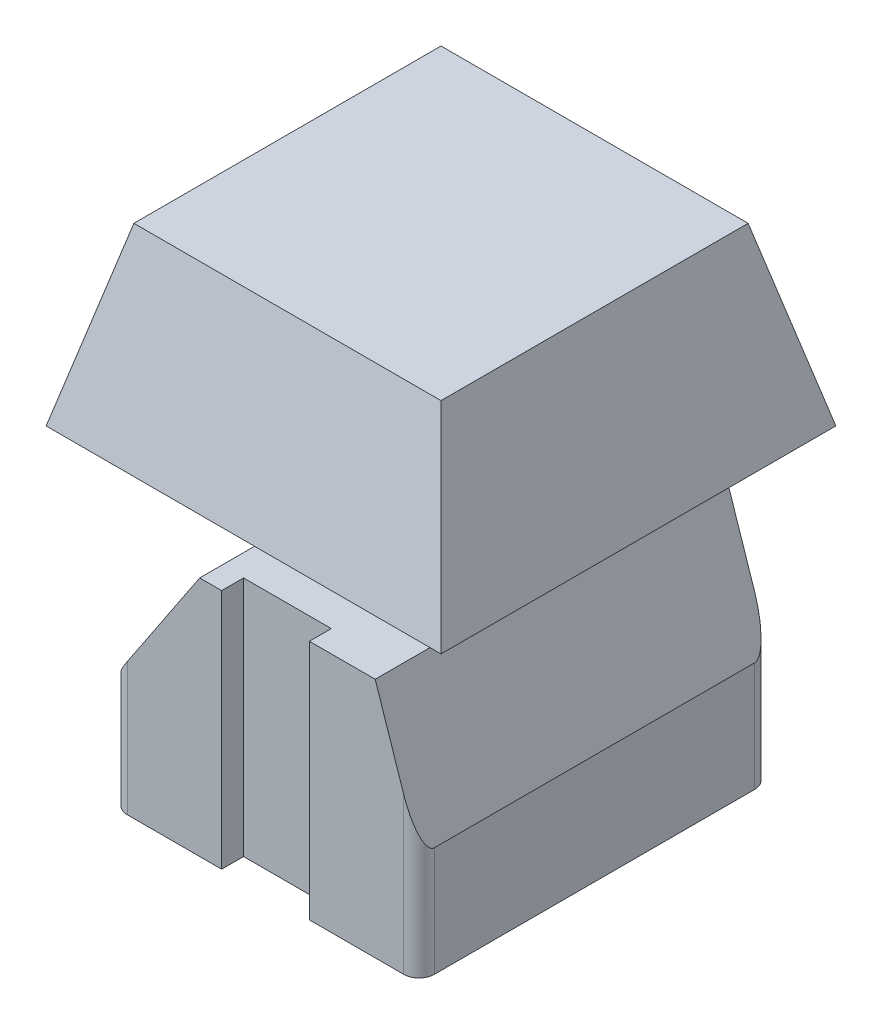
from build123d import *

# Parameters (mm, degrees)
BOSS_EXTRUDE1_DEPTH = 11
CUT_EXTRUDE1_DEPTH  = 18
CUT_EXTRUDE2_DEPTH  = 18
BOSS_EXTRUDE2_DEPTH = 3.5
BOSS_EXTRUDE3_DEPTH = 8
CUT_EXTRUDE4_DEPTH  = 27
CUT_EXTRUDE5_DEPTH  = 27
SKETCH11_W          = 14.6
SKETCH11_H          = 0.1
BOSS_EXTRUDE4_DEPTH = 0.1


with BuildPart() as part:
    # Sketch1 → Boss-Extrude1 (new body)
    with BuildSketch(Plane(origin=(0, 0, 0), x_dir=(1, 0, 0), z_dir=(0, 1, 0))):
        with BuildLine():
            Line((-6.3, -8), (-2, -8))
            Line((-2, -8), (-2, -7))
            Line((-2, -7), (2, -7))
            Line((2, -7), (2, -8))
            Line((2, -8), (6.3, -8))
            ThreePointArc((6.3, -8), (6.794974747, -7.794974747), (7, -7.3))
            Line((7, -7.3), (7, 7.3))
            ThreePointArc((7, 7.3), (6.794974747, 7.794974747), (6.3, 8))
            Line((6.3, 8), (2, 8))
            Line((2, 8), (2, 7))
            Line((2, 7), (-2, 7))
            Line((-2, 7), (-2, 8))
            Line((-2, 8), (-6.3, 8))
            ThreePointArc((-6.3, 8), (-6.794974747, 7.794974747), (-7, 7.3))
            Line((-7, 7.3), (-7, -7.3))
            ThreePointArc((-7, -7.3), (-6.794974747, -7.794974747), (-6.3, -8))
        make_face()
    extrude(amount=BOSS_EXTRUDE1_DEPTH)

    # Sketch2 → Cut-Extrude1 (cut)
    with BuildSketch(Plane.XY.offset(8)):
        Polygon((-3, 11), (-7, 5), (-7, 11), align=None)
    extrude(amount=-CUT_EXTRUDE1_DEPTH, mode=Mode.SUBTRACT)

    # Sketch3 → Cut-Extrude2 (cut)
    with BuildSketch(Plane.XY.offset(8)):
        Polygon((5, 11), (7, 5), (7, 11), align=None)
    extrude(amount=-CUT_EXTRUDE2_DEPTH, mode=Mode.SUBTRACT)

    # Sketch4 → Boss-Extrude2 (add)
    with BuildSketch(Plane(origin=(0, 11, 0), x_dir=(1, 0, 0), z_dir=(0, 1, 0))):
        Polygon((-0.75, 0.75), (-0.75, 2), (0.75, 2), (0.75, 0.75), (2, 0.75), (2, -0.75), (0.75, -0.75), (0.75, -2), (-0.75, -2), (-0.75, -0.75), (-2, -0.75), (-2, 0.75), align=None)
    extrude(amount=BOSS_EXTRUDE2_DEPTH)

    # Sketch7 → Boss-Extrude3 (add)
    with BuildSketch(Plane(origin=(0, 14.5, 0), x_dir=(1, 0, 0), z_dir=(0, 1, 0))):
        Polygon((9, -9), (-9, -9), (-9, 9), (0, 9), (9, 9), align=None)
    extrude(amount=BOSS_EXTRUDE3_DEPTH)

    # Sketch10 → Cut-Extrude4 (cut)
    with BuildSketch(Plane.ZY.offset(9)):
        Polygon((-9, 22.5), (-7, 22.5), (-9, 14.5), align=None)
        Polygon((7, 22.5), (9, 22.5), (9, 14.5), align=None)
    extrude(amount=-CUT_EXTRUDE4_DEPTH, mode=Mode.SUBTRACT)

    # Sketch8 → Cut-Extrude5 (cut)
    with BuildSketch(Plane(origin=(0, 0, -9), x_dir=(-1, 0, 0), z_dir=(0, 0, -1))):
        Polygon((9, 22.5), (7, 22.5), (9, 14.5), align=None)
        Polygon((-9, 22.5), (-7, 22.5), (-9, 14.5), align=None)
    extrude(amount=-CUT_EXTRUDE5_DEPTH, mode=Mode.SUBTRACT)

    # Sketch11 → Boss-Extrude4 (add)
    with BuildSketch(Plane.ZY.offset(7)):
        with Locations((0, 4.95)):
            Rectangle(SKETCH11_W, SKETCH11_H)
    extrude(amount=BOSS_EXTRUDE4_DEPTH)


solid = part.part
